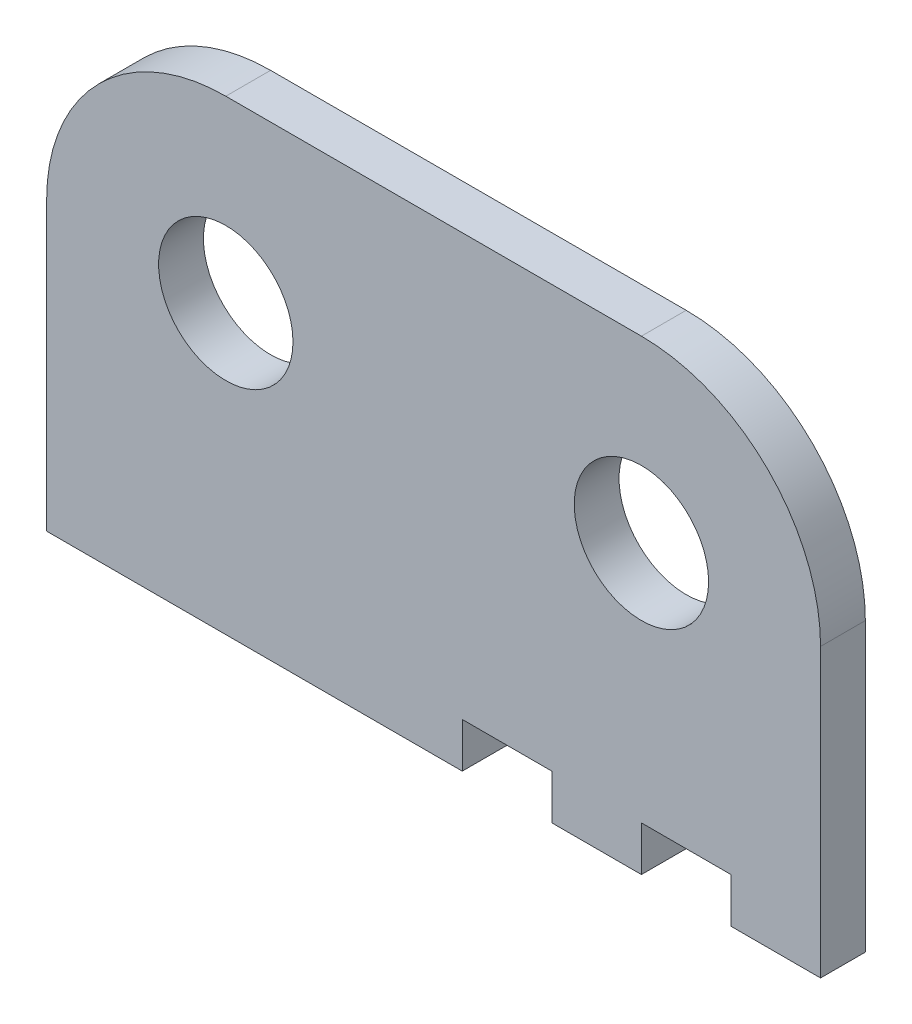
from build123d import *

# Parameters (mm, degrees)
SKETCH1_R           = 4.7625
BOSS_EXTRUDE1_DEPTH = 3.175
SKETCH2_W           = 6.35
SKETCH2_H           = 3.175
CUT_EXTRUDE1_DEPTH  = 3.175


with BuildPart() as part:
    # Sketch1 → Boss-Extrude1 (new body)
    with BuildSketch(Plane.XY):
        with BuildLine():
            Line((33.387675642, 20.35683), (33.387675642, 0))
            Line((33.387675642, 0), (-21.476324358, 0))
            Line((-21.476324358, 0), (-21.476324358, 20.35683))
            ThreePointArc((-21.476324358, 20.35683), (-17.756580479, 29.337086121), (-8.776324358, 33.05683))
            Line((-8.776324358, 33.05683), (20.687675642, 33.05683))
            ThreePointArc((20.687675642, 33.05683), (29.667931764, 29.337086121), (33.387675642, 20.35683))
        make_face()
        with Locations((20.687675642, 20.35683)):
            Circle(SKETCH1_R, mode=Mode.SUBTRACT)
        with Locations((-8.776324358, 20.35683)):
            Circle(SKETCH1_R, mode=Mode.SUBTRACT)
    extrude(amount=BOSS_EXTRUDE1_DEPTH)

    # Sketch2 → Cut-Extrude1 (cut)
    with BuildSketch(Plane.XZ):
        with Locations((23.862675642, 1.5875)):
            Rectangle(SKETCH2_W, SKETCH2_H)
        with Locations((11.162675642, 1.5875)):
            Rectangle(SKETCH2_W, SKETCH2_H)
    extrude(amount=-CUT_EXTRUDE1_DEPTH, mode=Mode.SUBTRACT)


solid = part.part
